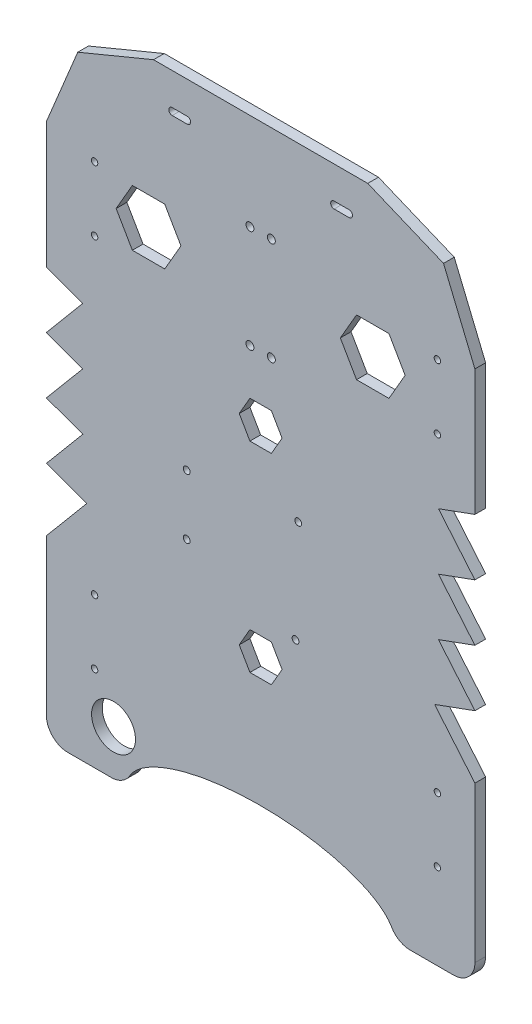
from build123d import *

# Parameters (mm, degrees)
SKETCH_1_R          = 1.6
EXTRUDE_1_DEPTH     = 5
CUT_EXTRUDE_1_DEPTH = 10
SKETCH_3_R          = 1.85
CUT_EXTRUDE_2_DEPTH = 10
SKETCH_4_R          = 10.25
CUT_EXTRUDE_3_DEPTH = 10
SKETCH_5_RX         = 62.536642564
SKETCH_5_RY         = 23.496138081
CUT_EXTRUDE_4_DEPTH = 10
FILLET_1_R          = 10
CUT_EXTRUDE_5_DEPTH = 10
CUT_EXTRUDE_6_DEPTH = 10
CUT_EXTRUDE_7_DEPTH = 10
CUT_EXTRUDE_8_DEPTH = 10
CUT_EXTRUDE_9_DEPTH = 10


with BuildPart() as part:
    # 草图1 → 凸台-拉伸1 (new body)
    with BuildSketch(Plane.XY):
        with BuildLine():
            Line((100, -150), (-100, -150))
            Line((-100, -150), (-100, 100))
            ThreePointArc((-100, 100), (-85.355339059, 135.355339059), (-50, 150))
            Line((-50, 150), (50, 150))
            ThreePointArc((50, 150), (85.355339059, 135.355339059), (100, 100))
            Line((100, 100), (100, -150))
        make_face()
        with Locations((-34.521960573, -8.188147907)):
            Circle(SKETCH_1_R, mode=Mode.SUBTRACT)
        with Locations((17.550731265, -3.107088494)):
            Circle(SKETCH_1_R, mode=Mode.SUBTRACT)
        with Locations((16.284685109, -51.357276396)):
            Circle(SKETCH_1_R, mode=Mode.SUBTRACT)
        with Locations((-34.521960573, -36.128147907)):
            Circle(SKETCH_1_R, mode=Mode.SUBTRACT)
    extrude(amount=-EXTRUDE_1_DEPTH)

    # 草图2 → 切除-拉伸1 (cut)
    with BuildSketch(Plane.XY):
        with BuildLine():
            Line((-77.5, 93.5), (-77.5, 95))
            Line((-77.5, 95), (-76, 95))
            ThreePointArc((-76, 95), (-78.560660172, 96.060660172), (-77.5, 93.5))
        make_face()
        with BuildLine():
            Line((-76, 95), (-77.5, 95))
            Line((-77.5, 95), (-77.5, 93.5))
            ThreePointArc((-77.5, 93.5), (-76.439339828, 93.939339828), (-76, 95))
        make_face()
        with BuildLine():
            ThreePointArc((-76, 65), (-76.439339828, 66.060660172), (-77.5, 66.5))
            Line((-77.5, 66.5), (-77.5, 65))
            Line((-77.5, 65), (-76, 65))
        make_face()
        with BuildLine():
            Line((-77.5, 65), (-77.5, 66.5))
            ThreePointArc((-77.5, 66.5), (-78.560660172, 63.939339828), (-76, 65))
            Line((-76, 65), (-77.5, 65))
        make_face()
        with BuildLine():
            ThreePointArc((84, 95), (82.5, 96.5), (81, 95))
            Line((81, 95), (82.5, 95))
            Line((82.5, 95), (82.5, 93.5))
            ThreePointArc((82.5, 93.5), (83.560660172, 93.939339828), (84, 95))
        make_face()
        with BuildLine():
            Line((82.5, 95), (81, 95))
            ThreePointArc((81, 95), (81.439339828, 93.939339828), (82.5, 93.5))
            Line((82.5, 93.5), (82.5, 95))
        make_face()
        with BuildLine():
            ThreePointArc((84, 65), (83.560660172, 66.060660172), (82.5, 66.5))
            Line((82.5, 66.5), (82.5, 65))
            Line((82.5, 65), (81, 65))
            ThreePointArc((81, 65), (82.5, 63.5), (84, 65))
        make_face()
        with BuildLine():
            Line((82.5, 65), (82.5, 66.5))
            ThreePointArc((82.5, 66.5), (81.439339828, 66.060660172), (81, 65))
            Line((81, 65), (82.5, 65))
        make_face()
        with BuildLine():
            ThreePointArc((84, -80), (82.5, -78.5), (81, -80))
            Line((81, -80), (82.5, -80))
            Line((82.5, -80), (82.5, -81.5))
            ThreePointArc((82.5, -81.5), (83.560660172, -81.060660172), (84, -80))
        make_face()
        with BuildLine():
            Line((82.5, -80), (81, -80))
            ThreePointArc((81, -80), (81.439339828, -81.060660172), (82.5, -81.5))
            Line((82.5, -81.5), (82.5, -80))
        make_face()
        with BuildLine():
            ThreePointArc((84, -110), (83.560660172, -108.939339828), (82.5, -108.5))
            Line((82.5, -108.5), (82.5, -110))
            Line((82.5, -110), (81, -110))
            ThreePointArc((81, -110), (82.5, -111.5), (84, -110))
        make_face()
        with BuildLine():
            Line((82.5, -110), (82.5, -108.5))
            ThreePointArc((82.5, -108.5), (81.439339828, -108.939339828), (81, -110))
            Line((81, -110), (82.5, -110))
        make_face()
        with BuildLine():
            ThreePointArc((-76, -110), (-76.439339828, -108.939339828), (-77.5, -108.5))
            Line((-77.5, -108.5), (-77.5, -110))
            Line((-77.5, -110), (-76, -110))
        make_face()
        with BuildLine():
            Line((-77.5, -110), (-77.5, -108.5))
            ThreePointArc((-77.5, -108.5), (-78.560660172, -111.060660172), (-76, -110))
            Line((-76, -110), (-77.5, -110))
        make_face()
        with BuildLine():
            Line((-77.5, -81.5), (-77.5, -80))
            Line((-77.5, -80), (-76, -80))
            ThreePointArc((-76, -80), (-78.560660172, -78.939339828), (-77.5, -81.5))
        make_face()
        with BuildLine():
            Line((-76, -80), (-77.5, -80))
            Line((-77.5, -80), (-77.5, -81.5))
            ThreePointArc((-77.5, -81.5), (-76.439339828, -81.060660172), (-76, -80))
        make_face()
    extrude(amount=-CUT_EXTRUDE_1_DEPTH, mode=Mode.SUBTRACT)

    # 草图3 → 切除-拉伸2 (cut)
    with BuildSketch(Plane.XY):
        with Locations((-5, 105)):
            Circle(SKETCH_3_R)
        with Locations((5, 105)):
            Circle(SKETCH_3_R)
        with Locations((-5, 57)):
            Circle(SKETCH_3_R)
        with Locations((5, 57)):
            Circle(SKETCH_3_R)
    extrude(amount=-CUT_EXTRUDE_2_DEPTH, mode=Mode.SUBTRACT)

    # 草图4 → 切除-拉伸3 (cut)
    with BuildSketch(Plane.XY):
        with Locations((-68.667685953, -128.956279274)):
            Circle(SKETCH_4_R)
    extrude(amount=-CUT_EXTRUDE_3_DEPTH, mode=Mode.SUBTRACT)

    # 草图5 → 切除-拉伸4 (cut)
    with BuildSketch(Plane.XY):
        with Locations((0, -150)):
            Ellipse(SKETCH_5_RX, SKETCH_5_RY)
    extrude(amount=-CUT_EXTRUDE_4_DEPTH, mode=Mode.SUBTRACT)

    # 圆角1
    fillet_1_edges = [part.edges().sort_by_distance(p)[0] for p in [
        (100, -150, -2.5),
        (62.536642564, -150, -2.5),
        (-62.536642564, -150, -2.5),
        (-100, -150, -2.5),
    ]]
    fillet(fillet_1_edges, radius=FILLET_1_R)

    # 草图6 → 切除-拉伸5 (cut)
    with BuildSketch(Plane.XY):
        Polygon((44.756616737, 68.037030505), (37.194996558, 81.134140843), (44.756616737, 94.231251181), (59.879857096, 94.231251181), (67.441477275, 81.134140843), (59.879857096, 68.037030505), align=None)
        Polygon((-37.194996558, 81.134140843), (-44.756616737, 94.231251181), (-59.879857096, 94.231251181), (-67.441477275, 81.134140843), (-59.879857096, 68.037030505), (-44.756616737, 68.037030505), align=None)
    extrude(amount=-CUT_EXTRUDE_5_DEPTH, mode=Mode.SUBTRACT)

    # 草图9 → 切除-拉伸6 (cut)
    with BuildSketch(Plane.XY):
        Polygon((-83, 35), (-100, 41.187493983), (-100, 14.740188926), align=None)
        Polygon((-83, 8.552694943), (-100, 14.740188926), (-100, -11.707116131), align=None)
        Polygon((-83, -17.894610113), (-100, -11.707116131), (-100, -38.154421187), align=None)
        Polygon((-81.191926789, -45), (-100, -38.154421187), (-100, -67.414588819), align=None)
        Polygon((100, -38.154421187), (81.191926789, -45), (100, -67.414588819), align=None)
        Polygon((83, -17.894610113), (100, -38.154421187), (100, -11.707116131), align=None)
        Polygon((83, 8.552694943), (100, -11.707116131), (100, 14.740188926), align=None)
        Polygon((83, 35), (100, 14.740188926), (100, 41.187493983), align=None)
    extrude(amount=-CUT_EXTRUDE_6_DEPTH, mode=Mode.SUBTRACT)

    # 草图10 → 切除-拉伸7 (cut)
    with BuildSketch(Plane.XY):
        Polygon((10, 27), (5, 35.660254038), (-5, 35.660254038), (-10, 27), (-5, 18.339745962), (5, 18.339745962), align=None)
        Polygon((10, -66.503861919), (5, -57.843607881), (-5, -57.843607881), (-10, -66.503861919), (-5, -75.164115957), (5, -75.164115957), align=None)
    extrude(amount=-CUT_EXTRUDE_7_DEPTH, mode=Mode.SUBTRACT)

    # 草图12 → 切除-拉伸8 (cut)
    with BuildSketch(Plane(origin=(0, 0, -5), x_dir=(-1, 0, 0), z_dir=(0, 0, -1))):
        with BuildLine():
            ThreePointArc((-85.355339059, 135.355339059), (-96.193976626, 119.134171618), (-100, 100))
            Line((-100, 100), (-85.355339059, 135.355339059))
        make_face()
        with BuildLine():
            ThreePointArc((-50, 150), (-69.134171618, 146.193976626), (-85.355339059, 135.355339059))
            Line((-85.355339059, 135.355339059), (-50, 150))
        make_face()
        with BuildLine():
            ThreePointArc((85.355339059, 135.355339059), (69.134171618, 146.193976626), (50, 150))
            Line((50, 150), (85.355339059, 135.355339059))
        make_face()
        with BuildLine():
            Line((85.355339059, 135.355339059), (100, 100))
            ThreePointArc((100, 100), (96.193976626, 119.134171618), (85.355339059, 135.355339059))
        make_face()
    extrude(amount=-CUT_EXTRUDE_8_DEPTH, mode=Mode.SUBTRACT)

    # 草图13 → 切除-拉伸9 (cut)
    with BuildSketch(Plane(origin=(0, 0, -5), x_dir=(-1, 0, 0), z_dir=(0, 0, -1))):
        with BuildLine():
            Line((-41.29, 131.8), (-34.29, 131.8))
            ThreePointArc((-34.29, 131.8), (-32.69, 133.4), (-34.29, 135))
            Line((-34.29, 135), (-41.29, 135))
            ThreePointArc((-41.29, 135), (-42.89, 133.4), (-41.29, 131.8))
        make_face()
        with BuildLine():
            ThreePointArc((34.29, 131.8), (32.69, 133.4), (34.29, 135))
            Line((34.29, 135), (41.29, 135))
            ThreePointArc((41.29, 135), (42.89, 133.4), (41.29, 131.8))
            Line((41.29, 131.8), (34.29, 131.8))
        make_face()
    extrude(amount=-CUT_EXTRUDE_9_DEPTH, mode=Mode.SUBTRACT)


solid = part.part
